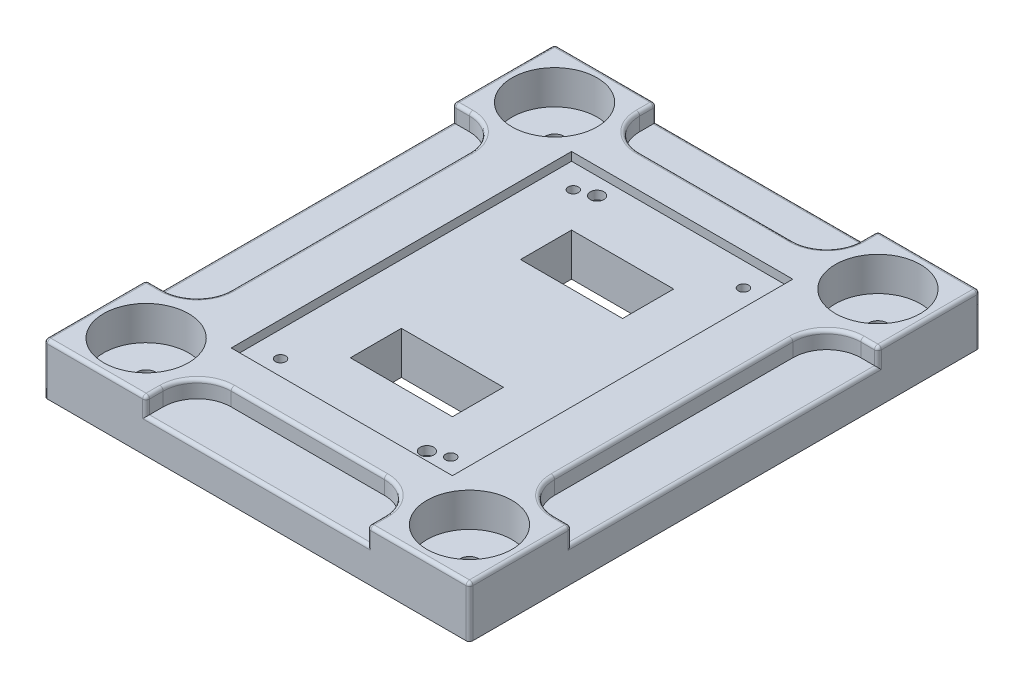
from build123d import *

# Parameters (mm, degrees)
SKETCH1_W                                           = 250
SKETCH1_H                                           = 300
BOSS_EXTRUDE1_DEPTH                                 = 30
SKETCH2_W                                           = 60
SKETCH2_H                                           = 30
CUT_EXTRUDE1_DEPTH                                  = 246
SKETCH4_W                                           = 130
SKETCH4_H                                           = 200
CUT_EXTRUDE2_DEPTH                                  = 5
CBORE_FOR_M5_HEX_SOCKET_HEAD_CAP_SCREW1_D           = 6
CBORE_FOR_M5_HEX_SOCKET_HEAD_CAP_SCREW1_DEPTH       = 30
CBORE_FOR_M5_HEX_SOCKET_HEAD_CAP_SCREW1_CBORE_D     = 8
CBORE_FOR_M5_HEX_SOCKET_HEAD_CAP_SCREW1_CBORE_DEPTH = 6
CBORE_FOR_M5_HEX_SOCKET_HEAD_CAP_SCREW1_TIP         = 1.802581857
CUT_EXTRUDE4_DEPTH                                  = 10
FILLET1_R                                           = 2
FILLET2_R                                           = 2
FILLET3_R                                           = 2
FILLET4_R                                           = 2
FILLET5_R                                           = 2
FILLET7_R                                           = 2
FILLET8_R                                           = 2
FILLET9_R                                           = 2
FILLET10_R                                          = 2
FILLET11_R                                          = 2
FILLET12_R                                          = 2
FILLET13_R                                          = 2
FILLET14_R                                          = 2
FILLET15_R                                          = 2
FILLET16_R                                          = 2
FILLET17_R                                          = 2
SKETCH11_R                                          = 25
CUT_EXTRUDE5_DEPTH                                  = 20
CBORE_FOR_M5_HEX_HEAD_BOLT3_D                       = 11
CBORE_FOR_M5_HEX_HEAD_BOLT3_CBORE_D                 = 16
CBORE_FOR_M5_HEX_HEAD_BOLT3_CBORE_DEPTH             = 8
SKETCH26_R                                          = 4
CUT_EXTRUDE6_DEPTH                                  = 5


with BuildPart() as part:
    # Sketch1 → Boss-Extrude1 (new body)
    with BuildSketch(Plane(origin=(0, 0, 0), x_dir=(1, 0, 0), z_dir=(0, 1, 0))):
        Rectangle(SKETCH1_W, SKETCH1_H)
    extrude(amount=BOSS_EXTRUDE1_DEPTH)

    # Sketch2 → Cut-Extrude1 (cut)
    with BuildSketch(Plane(origin=(0, 30, 0), x_dir=(1, 0, 0), z_dir=(0, 1, 0))):
        with Locations((0, 50)):
            Rectangle(SKETCH2_W, SKETCH2_H)
        with Locations((0, -50)):
            Rectangle(SKETCH2_W, SKETCH2_H)
    extrude(amount=-CUT_EXTRUDE1_DEPTH, mode=Mode.SUBTRACT)

    # Sketch4 → Cut-Extrude2 (cut)
    with BuildSketch(Plane(origin=(0, 30, 0), x_dir=(1, 0, 0), z_dir=(0, 1, 0))):
        Rectangle(SKETCH4_W, SKETCH4_H)
    extrude(amount=-CUT_EXTRUDE2_DEPTH, mode=Mode.SUBTRACT)

    # CBORE for M5 Hex Socket Head Cap Screw1
    with Locations(Plane(origin=(50, 0, -86), x_dir=(0, 0, -1), z_dir=(0, -1, 0))):
        with Locations((0, 0), (0, -100), (-172, -100), (-172, 0)):
            CounterBoreHole(CBORE_FOR_M5_HEX_SOCKET_HEAD_CAP_SCREW1_D / 2, CBORE_FOR_M5_HEX_SOCKET_HEAD_CAP_SCREW1_CBORE_D / 2, CBORE_FOR_M5_HEX_SOCKET_HEAD_CAP_SCREW1_CBORE_DEPTH, depth=CBORE_FOR_M5_HEX_SOCKET_HEAD_CAP_SCREW1_DEPTH)
            with Locations((0, 0, -(CBORE_FOR_M5_HEX_SOCKET_HEAD_CAP_SCREW1_DEPTH + CBORE_FOR_M5_HEX_SOCKET_HEAD_CAP_SCREW1_TIP / 2))):  # 118° drill point
                Cone(0, CBORE_FOR_M5_HEX_SOCKET_HEAD_CAP_SCREW1_D / 2, CBORE_FOR_M5_HEX_SOCKET_HEAD_CAP_SCREW1_TIP, mode=Mode.SUBTRACT)

    # Sketch10 → Cut-Extrude4 (cut)
    with BuildSketch(Plane(origin=(0, 30, 0), x_dir=(1, 0, 0), z_dir=(0, 1, 0))):
        with BuildLine():
            Line((-125, 90), (-115, 90))
            ThreePointArc((-115, 90), (-100.857864376, 84.142135624), (-95, 70))
            Line((-95, 70), (-95, -70))
            ThreePointArc((-95, -70), (-100.857864376, -84.142135624), (-115, -90))
            Line((-115, -90), (-125, -90))
            Line((-125, -90), (-125, 90))
        make_face()
        with BuildLine():
            Line((-65, -150), (65, -150))
            Line((65, -150), (65, -140))
            ThreePointArc((65, -140), (59.142135624, -125.857864376), (45, -120))
            Line((45, -120), (-45, -120))
            ThreePointArc((-45, -120), (-59.142135624, -125.857864376), (-65, -140))
            Line((-65, -140), (-65, -150))
        make_face()
        with BuildLine():
            Line((125, -90), (115, -90))
            ThreePointArc((115, -90), (100.857864376, -84.142135624), (95, -70))
            Line((95, -70), (95, 70))
            ThreePointArc((95, 70), (100.857864376, 84.142135624), (115, 90))
            Line((115, 90), (125, 90))
            Line((125, 90), (125, -90))
        make_face()
        with BuildLine():
            Line((65, 150), (-65, 150))
            Line((-65, 150), (-65, 140))
            ThreePointArc((-65, 140), (-59.142135624, 125.857864376), (-45, 120))
            Line((-45, 120), (45, 120))
            ThreePointArc((45, 120), (59.142135624, 125.857864376), (65, 140))
            Line((65, 140), (65, 150))
        make_face()
    extrude(amount=-CUT_EXTRUDE4_DEPTH, mode=Mode.SUBTRACT)

    # Fillet1
    fillet1_edges = [part.edges().sort_by_distance(p)[0] for p in [
        (-65, 30, 145),
        (65, 30, 145),
        (59.142135624, 30, 125.857864376),
        (0, 30, 120),
        (-59.142135624, 30, 125.857864376),
    ]]
    fillet(fillet1_edges, radius=FILLET1_R)

    # Fillet2
    fillet2_edges = [part.edges().sort_by_distance(p)[0] for p in [
        (-65, 24, 150),
        (-96, 30, 150),
        (-65.585786438, 29.414213562, 150),
    ]]
    fillet(fillet2_edges, radius=FILLET2_R)

    # Fillet3
    fillet3_edges = [part.edges().sort_by_distance(p)[0] for p in [
        (65, 24, 150),
        (96, 30, 150),
        (65.585786438, 29.414213562, 150),
    ]]
    fillet(fillet3_edges, radius=FILLET3_R)

    # Fillet4
    fillet4_edges = [part.edges().sort_by_distance(p)[0] for p in [
        (125, 14, 150),
        (125, 30, 119),
        (125, 29.414213562, 149.414213562),
    ]]
    fillet(fillet4_edges, radius=FILLET4_R)

    # Fillet5
    fillet5_edges = [part.edges().sort_by_distance(p)[0] for p in [
        (125, 24, 90),
        (120, 30, -90),
        (100.857864376, 30, -84.142135624),
        (95, 30, 0),
        (100.857864376, 30, 84.142135624),
        (119, 30, 90),
        (124.414213562, 29.414213562, 90),
    ]]
    fillet(fillet5_edges, radius=FILLET5_R)

    # Fillet7
    fillet7_edges = [part.edges().sort_by_distance(p)[0] for p in [
        (125, 24, -90),
        (125, 30, -121),
        (125, 29.414213562, -90.585786438),
    ]]
    fillet(fillet7_edges, radius=FILLET7_R)

    # Fillet8
    fillet8_edges = [part.edges().sort_by_distance(p)[0] for p in [
        (65, 30, -145),
        (-65, 30, -145),
        (-59.142135624, 30, -125.857864376),
        (0, 30, -120),
        (59.142135624, 30, -125.857864376),
    ]]
    fillet(fillet8_edges, radius=FILLET8_R)

    # Fillet9
    fillet9_edges = [part.edges().sort_by_distance(p)[0] for p in [
        (65, 24, -150),
        (125, 14, -150),
        (95, 30, -150),
        (124.414213562, 29.414213562, -150),
        (65.585786438, 29.414213562, -150),
    ]]
    fillet(fillet9_edges, radius=FILLET9_R)

    # Fillet10
    fillet10_edges = [part.edges().sort_by_distance(p)[0] for p in [
        (-65, 24, -150),
        (-96, 30, -150),
        (-65.585786438, 29.414213562, -150),
    ]]
    fillet(fillet10_edges, radius=FILLET10_R)

    # Fillet11
    fillet11_edges = [part.edges().sort_by_distance(p)[0] for p in [
        (-125, 14, -150),
        (-125, 30, -119),
        (-125, 29.414213562, -149.414213562),
    ]]
    fillet(fillet11_edges, radius=FILLET11_R)

    # Fillet12
    fillet12_edges = [part.edges().sort_by_distance(p)[0] for p in [
        (-125, 24, -90),
        (-120, 30, 90),
        (-100.857864376, 30, 84.142135624),
        (-95, 30, 0),
        (-100.857864376, 30, -84.142135624),
        (-119, 30, -90),
        (-124.414213562, 29.414213562, -90),
    ]]
    fillet(fillet12_edges, radius=FILLET12_R)

    # Fillet13
    fillet13_edges = [part.edges().sort_by_distance(p)[0] for p in [
        (-125, 24, 90),
        (-125, 14, 150),
        (-125, 29.414213562, 149.414213562),
        (-125, 30, 120),
        (-125, 29.414213562, 90.585786438),
    ]]
    fillet(fillet13_edges, radius=FILLET13_R)

    # Fillet14
    fillet14_edges = [part.edges().sort_by_distance(p)[0] for p in [
        (-125, 20, 0),
    ]]
    fillet(fillet14_edges, radius=FILLET14_R)

    # Fillet15
    fillet15_edges = [part.edges().sort_by_distance(p)[0] for p in [
        (0, 20, 150),
    ]]
    fillet(fillet15_edges, radius=FILLET15_R)

    # Fillet16
    fillet16_edges = [part.edges().sort_by_distance(p)[0] for p in [
        (125, 20, 0),
    ]]
    fillet(fillet16_edges, radius=FILLET16_R)

    # Fillet17
    fillet17_edges = [part.edges().sort_by_distance(p)[0] for p in [
        (0, 20, -150),
    ]]
    fillet(fillet17_edges, radius=FILLET17_R)

    # Sketch11 → Cut-Extrude5 (cut)
    with BuildSketch(Plane(origin=(0, 30, 0), x_dir=(1, 0, 0), z_dir=(0, 1, 0))):
        with Locations((-95, 120)):
            Circle(SKETCH11_R)
        with Locations((95, 120)):
            Circle(SKETCH11_R)
        with Locations((95, -120)):
            Circle(SKETCH11_R)
        with Locations((-95, -120)):
            Circle(SKETCH11_R)
    extrude(amount=-CUT_EXTRUDE5_DEPTH, mode=Mode.SUBTRACT)

    # CBORE for M5 Hex Head Bolt3 (through all)
    with Locations(Plane(origin=(95, 0, -120), x_dir=(0, 0, -1), z_dir=(0, -1, 0))):
        with Locations((0, 0), (0, -190), (-240, -190), (-240, 0)):
            CounterBoreHole(CBORE_FOR_M5_HEX_HEAD_BOLT3_D / 2, CBORE_FOR_M5_HEX_HEAD_BOLT3_CBORE_D / 2, CBORE_FOR_M5_HEX_HEAD_BOLT3_CBORE_DEPTH)

    # Sketch26 → Cut-Extrude6 (cut)
    with BuildSketch(Plane(origin=(0, 25, 0), x_dir=(1, 0, 0), z_dir=(0, 1, 0))):
        with Locations((40, -90)):
            Circle(SKETCH26_R)
        with Locations((-40, 90)):
            Circle(SKETCH26_R)
    extrude(amount=-CUT_EXTRUDE6_DEPTH, mode=Mode.SUBTRACT)


solid = part.part
